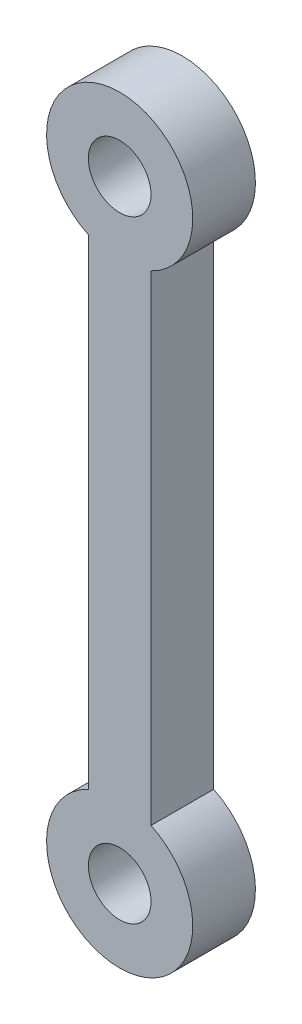
from build123d import *

# Parameters (mm, degrees)
ESTRUSIONE_ESTRUSIONE2_DEPTH = 3
TAGLIO_ESTRUSIONE7_START     = 3
SCHIZZO3_R                   = 1.5
TAGLIO_ESTRUSIONE7_DEPTH     = 4


with BuildPart() as part:
    # Schizzo2 → Estrusione-Estrusione2 (new body)
    with BuildSketch(Plane.XY):
        with BuildLine():
            Line((-34.111088775, -27.566511085), (-34.111088775, -50.566511085))
            ThreePointArc((-34.111088775, -50.566511085), (-32.611088775, -57.228788745), (-31.111088775, -50.566511085))
            Line((-31.111088775, -50.566511085), (-31.111088775, -27.566511085))
            ThreePointArc((-31.111088775, -27.566511085), (-32.611088775, -20.904233425), (-34.111088775, -27.566511085))
        make_face()
    extrude(amount=ESTRUSIONE_ESTRUSIONE2_DEPTH)

    # Schizzo3 → Taglio-Estrusione7 (cut, through all)
    with BuildSketch(Plane.XY.offset(TAGLIO_ESTRUSIONE7_START)):
        with Locations((-32.611088775, -24.404233425)):
            Circle(SCHIZZO3_R)
        with Locations((-32.611088775, -53.728788745)):
            Circle(SCHIZZO3_R)
    extrude(amount=-TAGLIO_ESTRUSIONE7_DEPTH, mode=Mode.SUBTRACT)


solid = part.part
